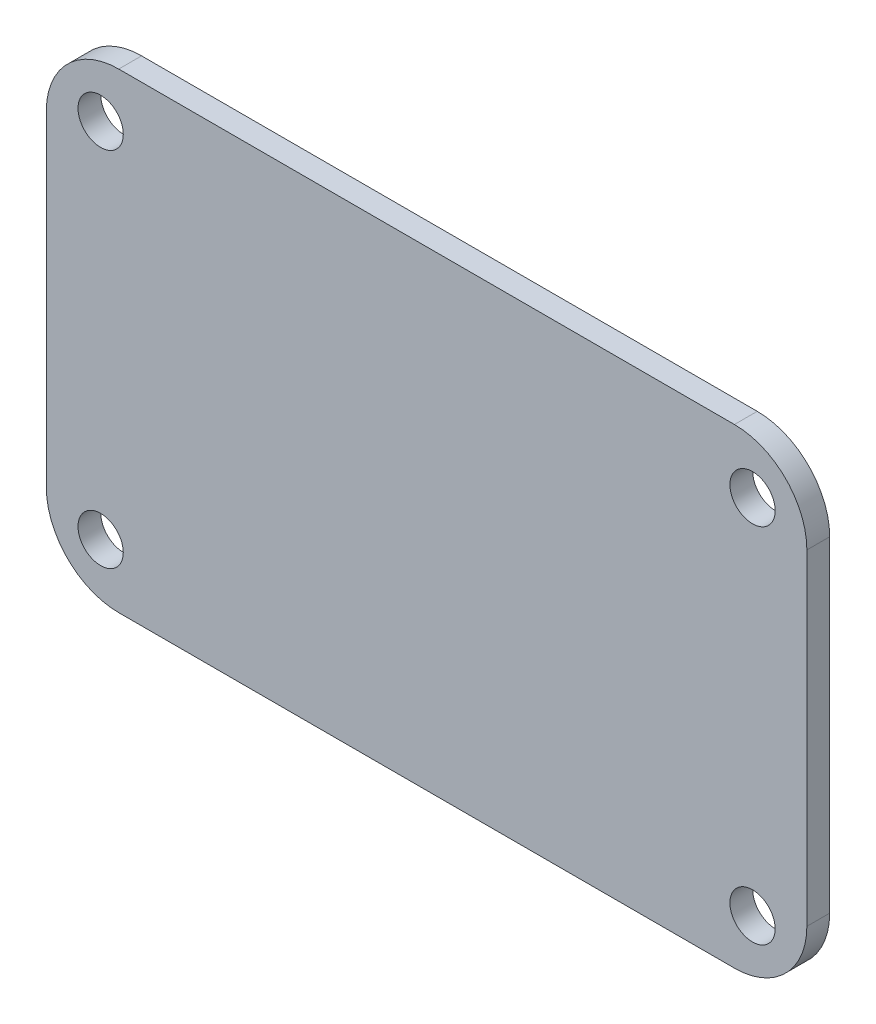
from build123d import *

# Parameters (mm, degrees)
BOSS_EXTRUDE1_DEPTH = 1.6002
SKETCH2_R           = 1.5875
CUT_EXTRUDE1_DEPTH  = 11.7602


with BuildPart() as part:
    # Sketch1 → Boss-Extrude1 (new body)
    with BuildSketch(Plane.XY):
        with BuildLine():
            Line((-21.59, 16.51), (21.59, 16.51))
            ThreePointArc((21.59, 16.51), (25.182102448, 15.022102448), (26.67, 11.43))
            Line((26.67, 11.43), (26.67, -11.43))
            ThreePointArc((26.67, -11.43), (25.182102448, -15.022102448), (21.59, -16.51))
            Line((21.59, -16.51), (-21.59, -16.51))
            ThreePointArc((-21.59, -16.51), (-25.182102448, -15.022102448), (-26.67, -11.43))
            Line((-26.67, -11.43), (-26.67, 11.43))
            ThreePointArc((-26.67, 11.43), (-25.182102448, 15.022102448), (-21.59, 16.51))
        make_face()
    extrude(amount=-BOSS_EXTRUDE1_DEPTH)

    # Sketch2 → Cut-Extrude1 (cut)
    with BuildSketch(Plane.XY):
        with Locations((-22.86, 12.7)):
            Circle(SKETCH2_R)
        with Locations((-22.86, -12.7)):
            Circle(SKETCH2_R)
        with Locations((22.86, 12.7)):
            Circle(SKETCH2_R)
        with Locations((22.86, -12.7)):
            Circle(SKETCH2_R)
    extrude(amount=-CUT_EXTRUDE1_DEPTH, mode=Mode.SUBTRACT)


solid = part.part
